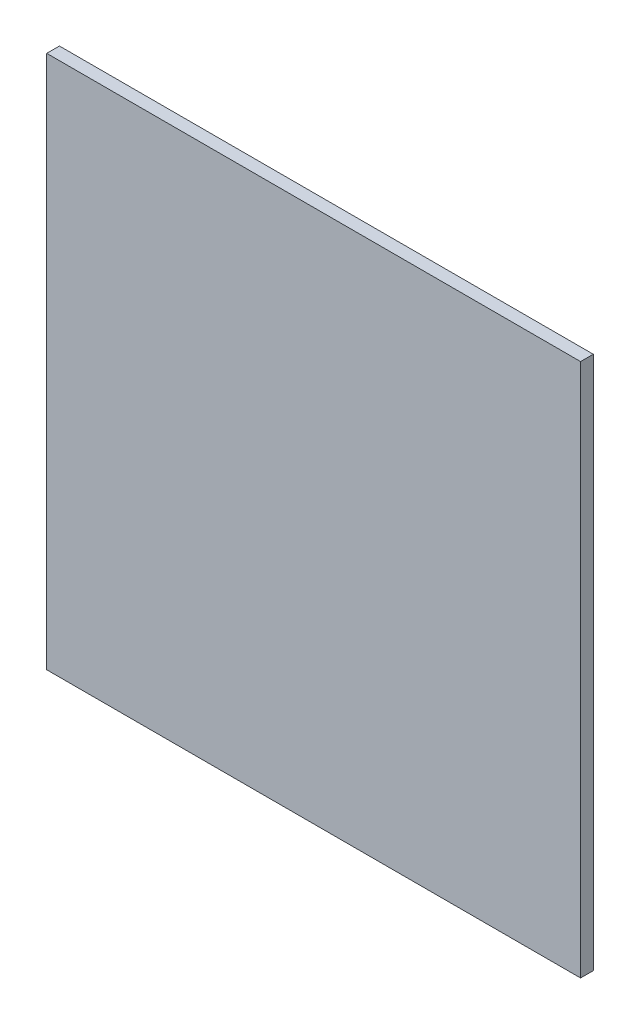
from build123d import *

# Parameters (mm, degrees)
SKETCH1_W           = 106.68
SKETCH1_H           = 106.68
BOSS_EXTRUDE1_DEPTH = 2.54


with BuildPart() as part:
    # Sketch1 → Boss-Extrude1 (new body)
    with BuildSketch(Plane.XY):
        with Locations((-53.34, 53.34)):
            Rectangle(SKETCH1_W, SKETCH1_H)
    extrude(amount=BOSS_EXTRUDE1_DEPTH)


solid = part.part
